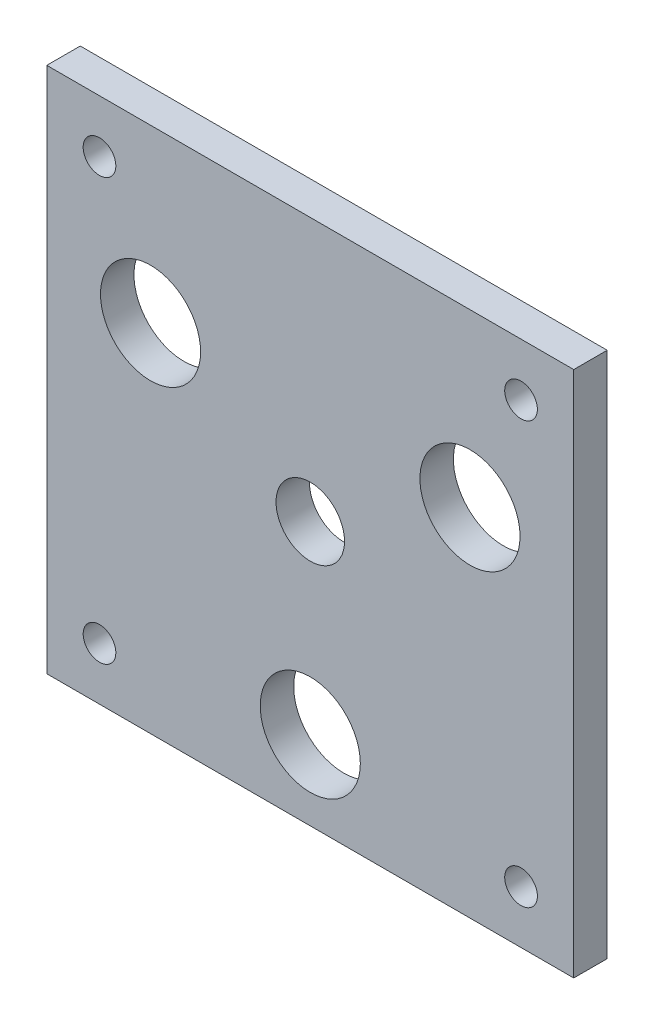
from build123d import *

# Parameters (mm, degrees)
CROQUIS1_W              = 100
CROQUIS1_H              = 100
CROQUIS1_R              = 9.5
SALIENTE_EXTRUIR1_DEPTH = 6.35
CORTAR_EXTRUIR1_REACH   = 8.35
CROQUIS2_R              = 6.5
CROQUIS2_R_2            = 3.1


with BuildPart() as part:
    # Croquis1 → Saliente-Extruir1 (new body)
    with BuildSketch(Plane.XY):
        Rectangle(CROQUIS1_W, CROQUIS1_H)
        with Locations((0, -35)):
            Circle(CROQUIS1_R, mode=Mode.SUBTRACT)
        with Locations((-30.310889132, 17.5)):
            Circle(CROQUIS1_R, mode=Mode.SUBTRACT)
        with Locations((30.310889132, 17.5)):
            Circle(CROQUIS1_R, mode=Mode.SUBTRACT)
    extrude(amount=SALIENTE_EXTRUIR1_DEPTH)

    # Croquis2 → Cortar-Extruir1 (cut, up to next)
    with BuildSketch(Plane.XY.offset(6.35), mode=Mode.PRIVATE) as cortar_extruir1_sk1:
        Circle(CROQUIS2_R)
    cortar_extruir1_tool1 = extrude(cortar_extruir1_sk1.sketch, amount=-CORTAR_EXTRUIR1_REACH, mode=Mode.PRIVATE) & part.part
    add(cortar_extruir1_tool1.solids().sort_by_distance((0, 0, 6.35))[0], mode=Mode.SUBTRACT)
    # Croquis2 → Cortar-Extruir1 (cut, up to next)
    with BuildSketch(Plane.XY.offset(6.35), mode=Mode.PRIVATE) as cortar_extruir1_sk2:
        with Locations((-40, 40)):
            Circle(CROQUIS2_R_2)
    cortar_extruir1_tool2 = extrude(cortar_extruir1_sk2.sketch, amount=-CORTAR_EXTRUIR1_REACH, mode=Mode.PRIVATE) & part.part
    add(cortar_extruir1_tool2.solids().sort_by_distance((-40, 40, 6.35))[0], mode=Mode.SUBTRACT)
    # Croquis2 → Cortar-Extruir1 (cut, up to next)
    with BuildSketch(Plane.XY.offset(6.35), mode=Mode.PRIVATE) as cortar_extruir1_sk3:
        with Locations((40, 40)):
            Circle(CROQUIS2_R_2)
    cortar_extruir1_tool3 = extrude(cortar_extruir1_sk3.sketch, amount=-CORTAR_EXTRUIR1_REACH, mode=Mode.PRIVATE) & part.part
    add(cortar_extruir1_tool3.solids().sort_by_distance((40, 40, 6.35))[0], mode=Mode.SUBTRACT)
    # Croquis2 → Cortar-Extruir1 (cut, up to next)
    with BuildSketch(Plane.XY.offset(6.35), mode=Mode.PRIVATE) as cortar_extruir1_sk4:
        with Locations((-40, -40)):
            Circle(CROQUIS2_R_2)
    cortar_extruir1_tool4 = extrude(cortar_extruir1_sk4.sketch, amount=-CORTAR_EXTRUIR1_REACH, mode=Mode.PRIVATE) & part.part
    add(cortar_extruir1_tool4.solids().sort_by_distance((-40, -40, 6.35))[0], mode=Mode.SUBTRACT)
    # Croquis2 → Cortar-Extruir1 (cut, up to next)
    with BuildSketch(Plane.XY.offset(6.35), mode=Mode.PRIVATE) as cortar_extruir1_sk5:
        with Locations((40, -40)):
            Circle(CROQUIS2_R_2)
    cortar_extruir1_tool5 = extrude(cortar_extruir1_sk5.sketch, amount=-CORTAR_EXTRUIR1_REACH, mode=Mode.PRIVATE) & part.part
    add(cortar_extruir1_tool5.solids().sort_by_distance((40, -40, 6.35))[0], mode=Mode.SUBTRACT)


solid = part.part
